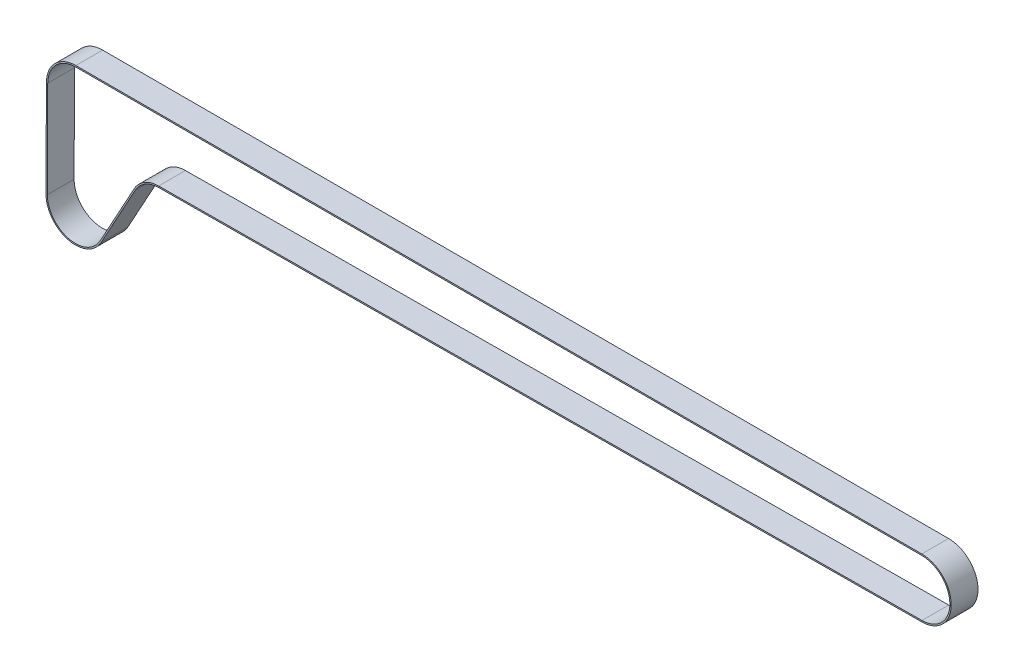
from build123d import *

# Parameters (mm, degrees)
EXTRUDE_THIN1_START = -2.5
EXTRUDE_THIN1_DEPTH = 5


with BuildPart() as part:
    # Sketch2 → Extrude-Thin1 (new, symmetric)
    with BuildSketch(Plane.XY.offset(EXTRUDE_THIN1_START)):
        with BuildLine():
            Line((-285.070155578, -13.000246093), (0.077171136, -10.999729297))
            ThreePointArc((0.077171136, -10.999729297), (10.999932323, 0.038585806), (0, 11))
            Line((0, 11), (-316, 11))
            ThreePointArc((-316, 11), (-323.762020666, 7.794295041), (-326.999905306, 0.045642761))
            Line((-326.999905306, 0.045642761), (-327.149905306, -36.104357239))
            ThreePointArc((-327.149905306, -36.104357239), (-318.900034366, -46.800695329), (-306.503020259, -41.435431097))
            Line((-306.503020259, -41.435431097), (-293.769981583, -18.195062639))
            ThreePointArc((-293.769981583, -18.195062639), (-290.126747116, -14.414170744), (-285.070155578, -13.000246093))
        make_face()
        with BuildLine():
            Line((-285.073663357, -12.500258398), (0.073663357, -10.499741602))
            ThreePointArc((0.073663357, -10.499741602), (10.499935399, 0.036831905), (0, 10.5))
            Line((0, 10.5), (-316, 10.5))
            ThreePointArc((-316, 10.5), (-323.409201545, 7.440008903), (-326.49990961, 0.04356809))
            Line((-326.49990961, 0.04356809), (-326.64990961, -36.10643191))
            ThreePointArc((-326.64990961, -36.10643191), (-318.775032804, -46.316572814), (-306.941519338, -41.195184229))
            Line((-306.941519338, -41.195184229), (-294.208480662, -17.954815771))
            ThreePointArc((-294.208480662, -17.954815771), (-290.383084472, -13.984879282), (-285.073663357, -12.500258398))
        make_face(mode=Mode.SUBTRACT)
    extrude(amount=EXTRUDE_THIN1_DEPTH, both=True)


solid = part.part
